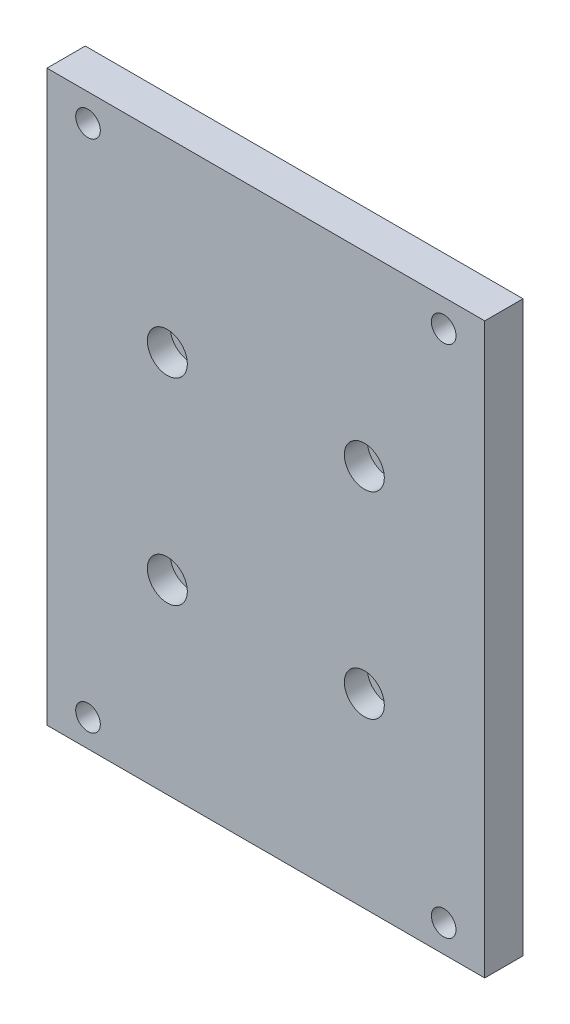
from build123d import *

# Parameters (mm, degrees)
SKETCH_2_W                = 80
SKETCH_2_H                = 104
SKETCH_2_R                = 2.25
EXTRUDE_1_DEPTH           = 7
HOLE_WIZARD_1_D           = 4.5
HOLE_WIZARD_1_CBORE_D     = 7.3
HOLE_WIZARD_1_CBORE_DEPTH = 4.2
CUT_EXTRUDE_1_DEPTH       = 2.5


with BuildPart() as part:
    # 草圖2 → 填料-伸長1 (new body)
    with BuildSketch(Plane.XY):
        Rectangle(SKETCH_2_W, SKETCH_2_H)
        with Locations((-18, 18)):
            Circle(SKETCH_2_R, mode=Mode.SUBTRACT)
        with Locations((-32.5, 47)):
            Circle(SKETCH_2_R, mode=Mode.SUBTRACT)
        with Locations((18, 18)):
            Circle(SKETCH_2_R, mode=Mode.SUBTRACT)
        with Locations((18, -18)):
            Circle(SKETCH_2_R, mode=Mode.SUBTRACT)
        with Locations((-18, -18)):
            Circle(SKETCH_2_R, mode=Mode.SUBTRACT)
        with Locations((32.5, 47)):
            Circle(SKETCH_2_R, mode=Mode.SUBTRACT)
        with Locations((32.5, -47)):
            Circle(SKETCH_2_R, mode=Mode.SUBTRACT)
        with Locations((-32.5, -47)):
            Circle(SKETCH_2_R, mode=Mode.SUBTRACT)
    extrude(amount=EXTRUDE_1_DEPTH)

    # 鑽孔1 (through all)
    with Locations(Plane(origin=(-18, 18, 7), x_dir=(1, 0, 0), z_dir=(0, 0, 1))):
        with Locations((0, 0), (36, 0), (36, -36), (0, -36)):
            CounterBoreHole(HOLE_WIZARD_1_D / 2, HOLE_WIZARD_1_CBORE_D / 2, HOLE_WIZARD_1_CBORE_DEPTH)

    # 草圖4 → 除料-伸長1 (cut)
    with BuildSketch(Plane(origin=(0, 0, 0), x_dir=(-1, 0, 0), z_dir=(0, 0, -1))):
        Polygon((-28.285343035, 47), (-30.392671517, 50.65), (-34.607328483, 50.65), (-36.714656965, 47), (-34.607328483, 43.35), (-30.392671517, 43.35), align=None)
        Polygon((30.392671517, 43.35), (28.285343035, 47), (30.392671517, 50.65), (34.607328483, 50.65), (36.714656965, 47), (34.607328483, 43.35), align=None)
        Polygon((28.285343035, -47), (30.392671517, -50.65), (34.607328483, -50.65), (36.714656965, -47), (34.607328483, -43.35), (30.392671517, -43.35), align=None)
        Polygon((-30.392671517, -43.35), (-28.285343035, -47), (-30.392671517, -50.65), (-34.607328483, -50.65), (-36.714656965, -47), (-34.607328483, -43.35), align=None)
    extrude(amount=-CUT_EXTRUDE_1_DEPTH, mode=Mode.SUBTRACT)


solid = part.part
